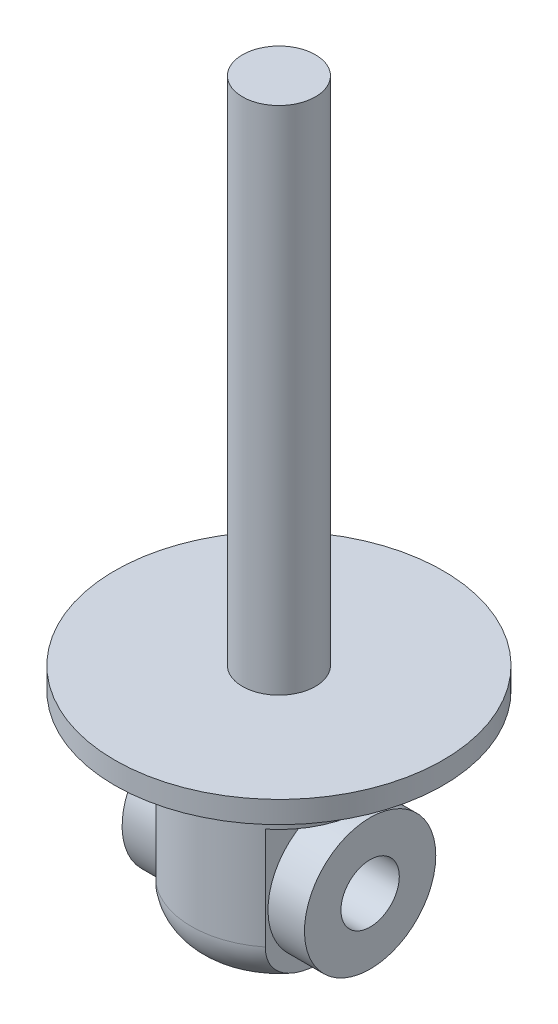
from build123d import *

# Parameters (mm, degrees)
SKETCH1_R               = 22.5
BOSS_EXTRUDE1_DEPTH     = 3
SKETCH2_R               = 5
BOSS_EXTRUDE2_DEPTH     = 70
SKETCH3_R               = 12
BOSS_EXTRUDE3_DEPTH     = 28
FILLET1_R               = 6
SKETCH4_W               = 21.865231439
SKETCH4_H               = 20
CUT_EXTRUDE1_DEPTH      = 23.5
CUT_EXTRUDE1_DEPTH_BACK = 23.5
SKETCH5_R               = 4
CUT_EXTRUDE3_DEPTH      = 16
CUT_EXTRUDE3_DEPTH_BACK = 31
SKETCH7_R               = 9
SKETCH7_R_2             = 4
BOSS_EXTRUDE4_DEPTH     = 12.5


with BuildPart() as part:
    # Sketch1 → Boss-Extrude1 (new body)
    with BuildSketch(Plane(origin=(0, 0, 0), x_dir=(1, 0, 0), z_dir=(0, 1, 0))):
        Circle(SKETCH1_R)
    extrude(amount=BOSS_EXTRUDE1_DEPTH)

    # Sketch2 → Boss-Extrude2 (add)
    with BuildSketch(Plane(origin=(0, 3, 0), x_dir=(1, 0, 0), z_dir=(0, 1, 0))):
        Circle(SKETCH2_R)
    extrude(amount=BOSS_EXTRUDE2_DEPTH)

    # Sketch3 → Boss-Extrude3 (add)
    with BuildSketch(Plane.XZ):
        Circle(SKETCH3_R)
    extrude(amount=BOSS_EXTRUDE3_DEPTH)

    # Fillet1
    fillet1_edges = [part.edges().sort_by_distance(p)[0] for p in [
        (-12, -28, 0),
    ]]
    fillet(fillet1_edges, radius=FILLET1_R)

    # Sketch4 → Cut-Extrude1 (cut, two sides)
    with BuildSketch(Plane.XY) as cut_extrude1_sk:
        with Locations((18.43261572, -18)):
            Rectangle(SKETCH4_W, SKETCH4_H)
        with Locations((-18.43261572, -18)):
            Rectangle(SKETCH4_W, SKETCH4_H)
    extrude(amount=CUT_EXTRUDE1_DEPTH, mode=Mode.SUBTRACT)
    extrude(cut_extrude1_sk.sketch, amount=-CUT_EXTRUDE1_DEPTH_BACK, mode=Mode.SUBTRACT)

    # Sketch5 → Cut-Extrude3 (cut, two sides)
    with BuildSketch(Plane(origin=(7.5, 0, 0), x_dir=(0, 0, -1), z_dir=(1, 0, 0))) as cut_extrude3_sk:
        with Locations((0, -17.809475225)):
            Circle(SKETCH5_R)
    extrude(amount=CUT_EXTRUDE3_DEPTH, mode=Mode.SUBTRACT)
    extrude(cut_extrude3_sk.sketch, amount=-CUT_EXTRUDE3_DEPTH_BACK, mode=Mode.SUBTRACT)

    # Sketch7 → Boss-Extrude4 (add, symmetric)
    with BuildSketch(Plane(origin=(0, 0, 0), x_dir=(0, 0, -1), z_dir=(1, 0, 0))):
        with Locations((0, -17.809475225)):
            Circle(SKETCH7_R)
        with Locations((0, -17.809475225)):
            Circle(SKETCH7_R_2, mode=Mode.SUBTRACT)
    extrude(amount=BOSS_EXTRUDE4_DEPTH, both=True)


solid = part.part
